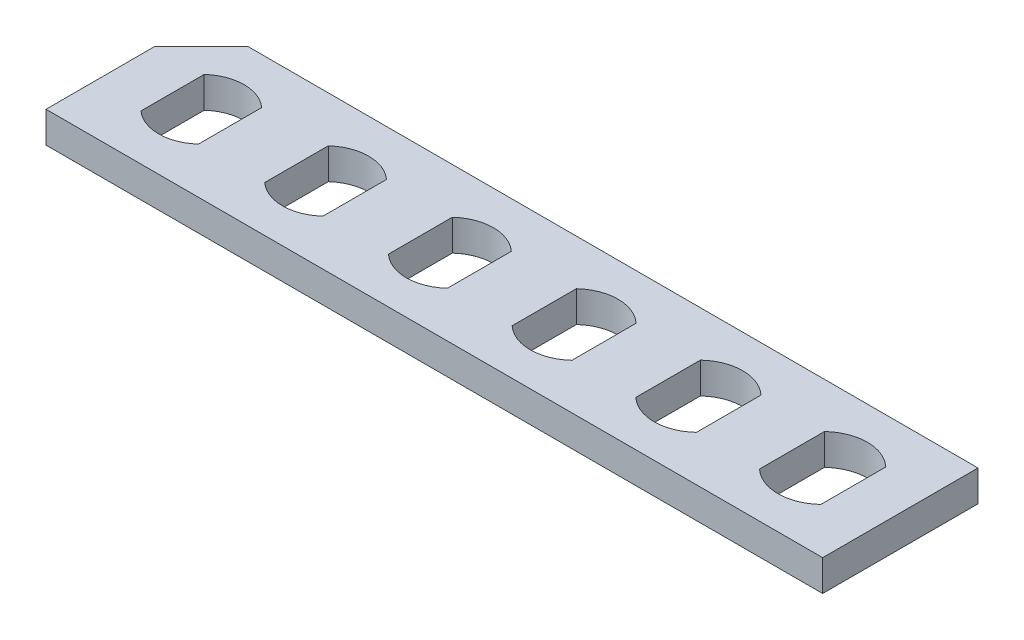
from build123d import *

# Parameters (mm, degrees)
SKETCH1_W           = 50
SKETCH1_H           = 10
BOSS_EXTRUDE1_DEPTH = 2
CUT_EXTRUDE1_DEPTH  = 3


with BuildPart() as part:
    # Sketch1 → Boss-Extrude1 (new body)
    with BuildSketch(Plane(origin=(0, 0, 0), x_dir=(1, 0, 0), z_dir=(0, 1, 0))):
        with Locations((25, 5)):
            Rectangle(SKETCH1_W, SKETCH1_H)
        with BuildLine():
            Line((3.15, 7.034698995), (3.15, 2.965301005))
            ThreePointArc((3.15, 2.965301005), (5, 2.25), (6.85, 2.965301005))
            Line((6.85, 2.965301005), (6.85, 7.034698995))
            ThreePointArc((6.85, 7.034698995), (5, 7.75), (3.15, 7.034698995))
        make_face(mode=Mode.SUBTRACT)
        with BuildLine():
            Line((11.125, 7.045727255), (11.125, 2.954272745))
            ThreePointArc((11.125, 2.954272745), (13, 2.225), (14.875, 2.954272745))
            Line((14.875, 2.954272745), (14.875, 7.045727255))
            ThreePointArc((14.875, 7.045727255), (13, 7.775), (11.125, 7.045727255))
        make_face(mode=Mode.SUBTRACT)
        with BuildLine():
            Line((19.1, 7.05669638), (19.1, 2.94330362))
            ThreePointArc((19.1, 2.94330362), (21, 2.2), (22.9, 2.94330362))
            Line((22.9, 2.94330362), (22.9, 7.05669638))
            ThreePointArc((22.9, 7.05669638), (21, 7.8), (19.1, 7.05669638))
        make_face(mode=Mode.SUBTRACT)
        with BuildLine():
            Line((27.075, 7.067607313), (27.075, 2.932392687))
            ThreePointArc((27.075, 2.932392687), (29, 2.175), (30.925, 2.932392687))
            Line((30.925, 2.932392687), (30.925, 7.067607313))
            ThreePointArc((30.925, 7.067607313), (29, 7.825), (27.075, 7.067607313))
        make_face(mode=Mode.SUBTRACT)
        with BuildLine():
            Line((38.95, 2.921539031), (38.95, 7.078460969))
            ThreePointArc((38.95, 7.078460969), (37, 7.85), (35.05, 7.078460969))
            Line((35.05, 7.078460969), (35.05, 2.921539031))
            ThreePointArc((35.05, 2.921539031), (37, 2.15), (38.95, 2.921539031))
        make_face(mode=Mode.SUBTRACT)
        with BuildLine():
            Line((46.975, 2.910741758), (46.975, 7.089258242))
            ThreePointArc((46.975, 7.089258242), (45, 7.875), (43.025, 7.089258242))
            Line((43.025, 7.089258242), (43.025, 2.910741758))
            ThreePointArc((43.025, 2.910741758), (45, 2.125), (46.975, 2.910741758))
        make_face(mode=Mode.SUBTRACT)
    extrude(amount=BOSS_EXTRUDE1_DEPTH)

    # Sketch2 → Cut-Extrude1 (cut, through all)
    with BuildSketch(Plane(origin=(0, 2, 0), x_dir=(1, 0, 0), z_dir=(0, 1, 0))):
        Polygon((0, 7), (3, 10), (0, 10), align=None)
    extrude(amount=-CUT_EXTRUDE1_DEPTH, mode=Mode.SUBTRACT)


solid = part.part
